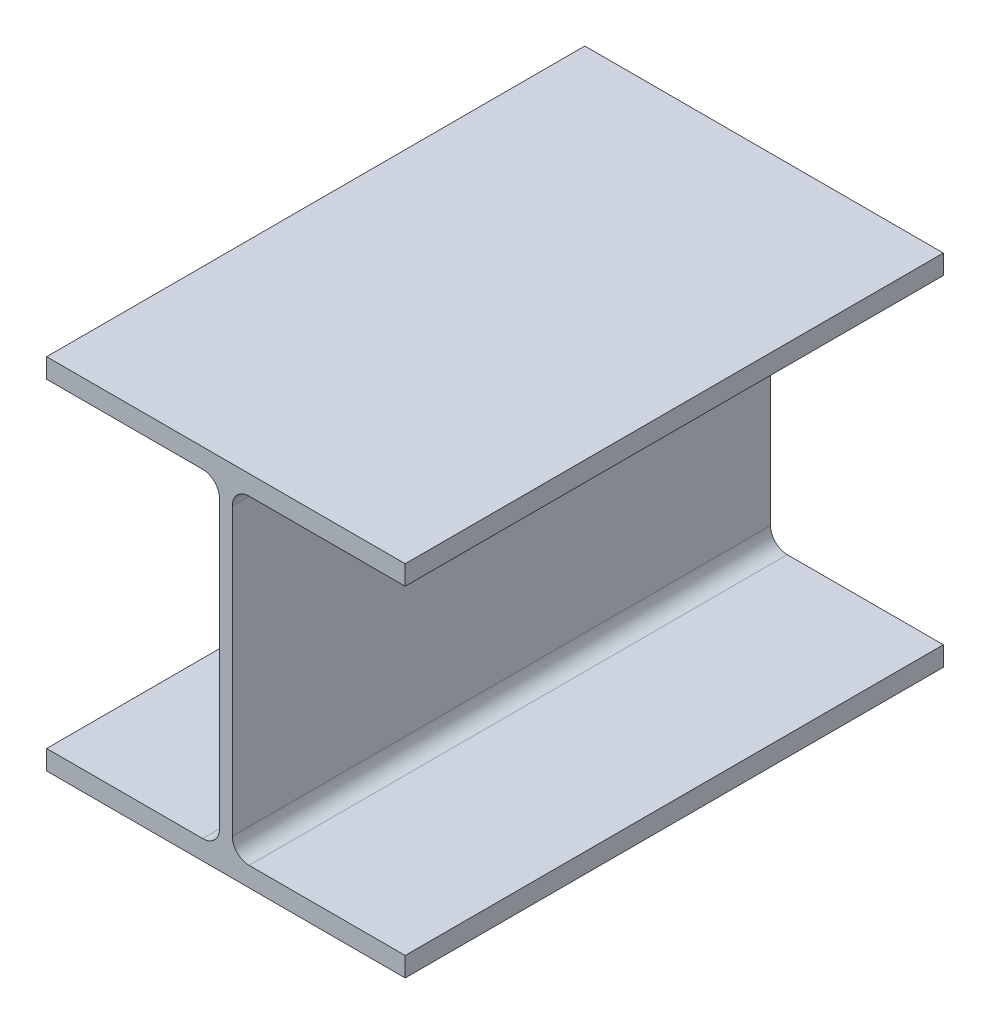
from build123d import *

# Parameters (mm, degrees)
BOSS_EXTRUDE1_DEPTH = 152.4
FILLET1_R           = 9.525


with BuildPart() as part:
    # Sketch2 → Boss-Extrude1 (new body, symmetric)
    with BuildSketch(Plane.XY):
        Polygon((-3.6195, 90.551), (-3.6195, -90.551), (-101.5365, -90.551), (-101.5365, -101.6), (101.5365, -101.6), (101.5365, -90.551), (3.6195, -90.551), (3.6195, 90.551), (101.5365, 90.551), (101.5365, 101.6), (-101.5365, 101.6), (-101.5365, 90.551), align=None)
    extrude(amount=BOSS_EXTRUDE1_DEPTH, both=True)

    # Fillet1
    fillet1_edges = [part.edges().sort_by_distance(p)[0] for p in [
        (-3.6195, -90.551, 0),
        (-3.6195, 90.551, 0),
        (3.6195, 90.551, 0),
        (3.6195, -90.551, 0),
    ]]
    fillet(fillet1_edges, radius=FILLET1_R)


solid = part.part
